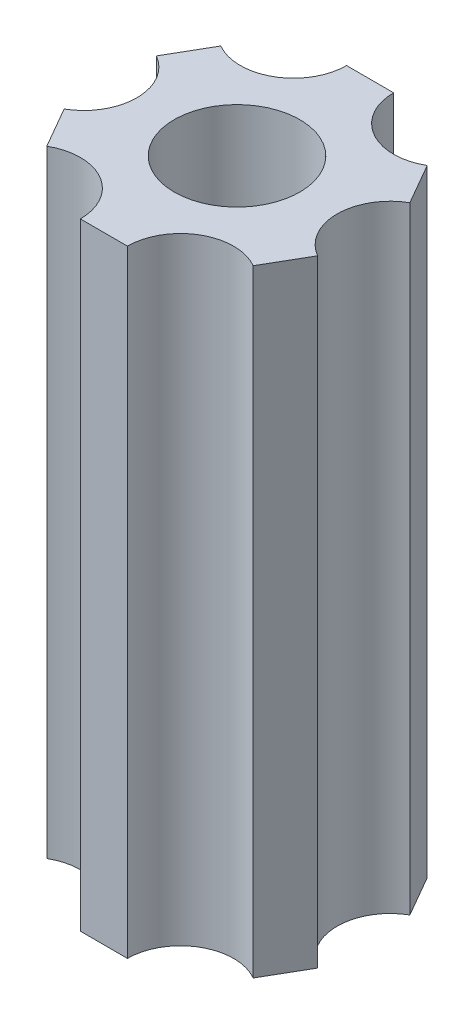
from build123d import *

# Parameters (mm, degrees)
BOSS_EXTRUDE1_DEPTH = 29.464
SKETCH2_R           = 3
CUT_EXTRUDE1_DEPTH  = 254


with BuildPart() as part:
    # Sketch1 → Boss-Extrude1 (new body)
    with BuildSketch(Plane(origin=(0, 0, 0), x_dir=(1, 0, 0), z_dir=(0, 1, 0))):
        with BuildLine():
            ThreePointArc((1.117349967, -6.351558659), (2.390405172, -4.153620888), (4.93040272, -4.15715015))
            Line((4.93040272, -4.15715015), (6.059286136, -2.208125873))
            ThreePointArc((6.059286136, -2.208125873), (4.792343793, -0.00665884), (6.065398997, 2.191278931))
            Line((6.065398997, 2.191278931), (4.941936169, 4.143432786))
            ThreePointArc((4.941936169, 4.143432786), (2.401938621, 4.146962048), (1.134996277, 6.348429081))
            Line((1.134996277, 6.348429081), (-1.117349967, 6.351558659))
            ThreePointArc((-1.117349967, 6.351558659), (-2.390405172, 4.153620888), (-4.93040272, 4.15715015))
            Line((-4.93040272, 4.15715015), (-6.059286136, 2.208125873))
            ThreePointArc((-6.059286136, 2.208125873), (-5.13175503, 1.27865958), (-4.792341341, 0.010188102))
            ThreePointArc((-4.792341341, 0.010188102), (-5.133519662, -1.261339807), (-6.065398997, -2.191278931))
            Line((-6.065398997, -2.191278931), (-4.941936169, -4.143432786))
            ThreePointArc((-4.941936169, -4.143432786), (-2.403465916, -4.14607814), (-1.134993825, -6.344899819))
            ThreePointArc((-1.134993825, -6.344899819), (-1.134994438, -6.346664451), (-1.134996277, -6.348429081))
            Line((-1.134996277, -6.348429081), (1.117349967, -6.351558659))
        make_face()
    extrude(amount=BOSS_EXTRUDE1_DEPTH)

    # Sketch2 → Cut-Extrude1 (cut)
    with BuildSketch(Plane(origin=(0, 29.464, 0), x_dir=(1, 0, 0), z_dir=(0, 1, 0))):
        Circle(SKETCH2_R)
    extrude(amount=-CUT_EXTRUDE1_DEPTH, mode=Mode.SUBTRACT)


solid = part.part
